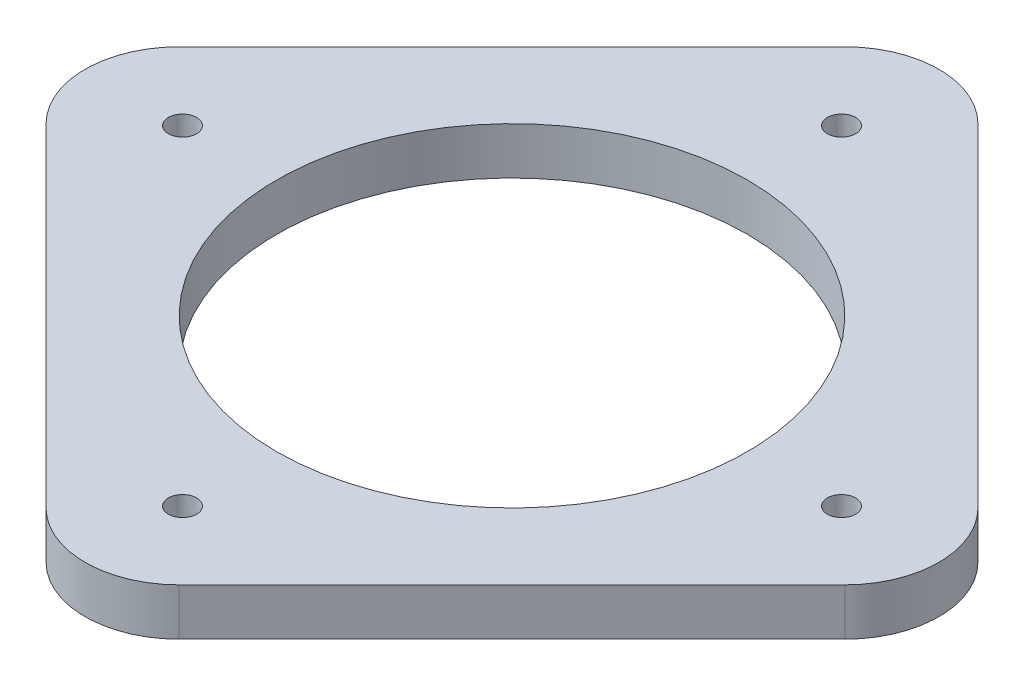
from build123d import *

# Parameters (mm, degrees)
CROQUIS1_R              = 25
CROQUIS1_R_2            = 1.5
SALIENTE_EXTRUIR1_DEPTH = 5


with BuildPart() as part:
    # Croquis1 → Saliente-Extruir1 (new body)
    with BuildSketch(Plane(origin=(0, 0, 0), x_dir=(1, 0, 0), z_dir=(0, 1, 0))):
        with BuildLine():
            Line((-42.426406871, -7.071067812), (-7.071067812, -42.426406871))
            ThreePointArc((-7.071067812, -42.426406871), (0, -45.355339059), (7.071067812, -42.426406871))
            Line((7.071067812, -42.426406871), (42.426406871, -7.071067812))
            ThreePointArc((42.426406871, -7.071067812), (45.355339059, 0), (42.426406871, 7.071067812))
            Line((42.426406871, 7.071067812), (7.071067812, 42.426406871))
            ThreePointArc((7.071067812, 42.426406871), (0, 45.355339059), (-7.071067812, 42.426406871))
            Line((-7.071067812, 42.426406871), (-42.426406871, 7.071067812))
            ThreePointArc((-42.426406871, 7.071067812), (-45.355339059, 0), (-42.426406871, -7.071067812))
        make_face()
        Circle(CROQUIS1_R, mode=Mode.SUBTRACT)
        with Locations((35, 0)):
            Circle(CROQUIS1_R_2, mode=Mode.SUBTRACT)
        with Locations((0, -35)):
            Circle(CROQUIS1_R_2, mode=Mode.SUBTRACT)
        with Locations((-35, 0)):
            Circle(CROQUIS1_R_2, mode=Mode.SUBTRACT)
        with Locations((0, 35)):
            Circle(CROQUIS1_R_2, mode=Mode.SUBTRACT)
    extrude(amount=SALIENTE_EXTRUIR1_DEPTH)


solid = part.part
